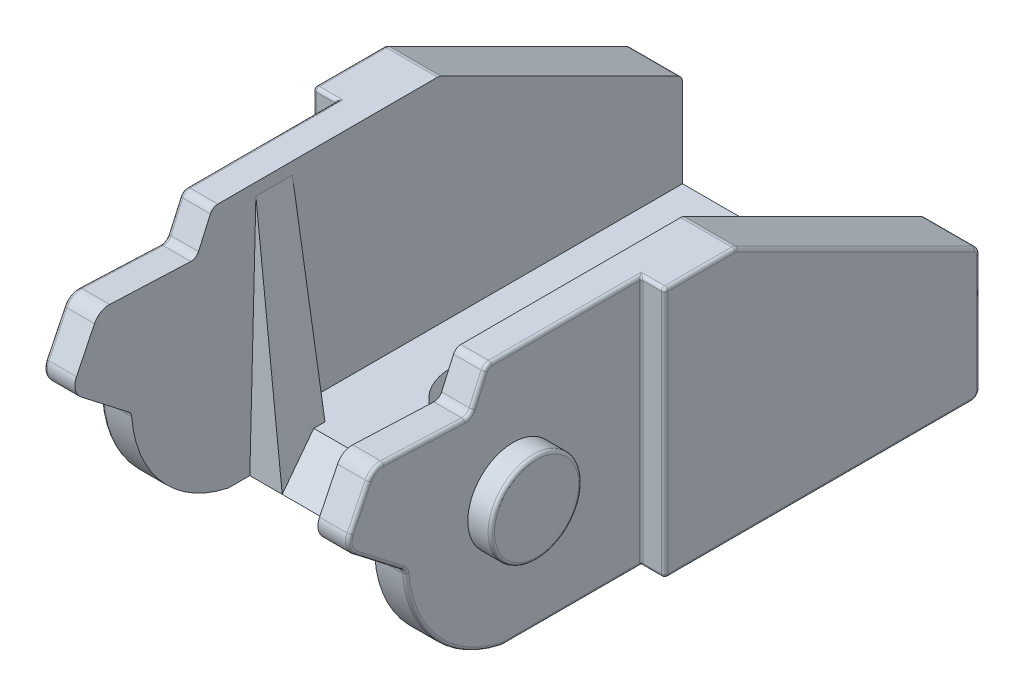
from build123d import *

# Parameters (mm, degrees)
SKETCH1_W               = 38
SKETCH1_H               = 15.5
BOSS_EXTRUDE1_DEPTH     = 10.85
CUT_EXTRUDE1_DEPTH      = 11.85
CUT_EXTRUDE1_DEPTH_BACK = 11.85
FILLET1_R               = 1
FILLET2_R               = 0.5
SKETCH4_R               = 2.8
CUT_EXTRUDE2_DEPTH      = 1.45
SKETCH5_W               = 15
SKETCH5_H               = 13.25
CUT_EXTRUDE3_DEPTH      = 38.495243704
CUT_EXTRUDE4_DEPTH      = 21.7
SKETCH8_W               = 15
SKETCH8_H               = 5.30714421
CUT_EXTRUDE5_DEPTH      = 16.5
CUT_EXTRUDE6_DEPTH      = 2.25
CUT_EXTRUDE6_TAPER      = -30
CUT_EXTRUDE7_DEPTH      = 15
BOSS_EXTRUDE2_DEPTH     = 2
CUT_EXTRUDE8_DEPTH      = 28.35
FILLET3_R               = 0.5
FILLET4_R               = 0.2
SKETCH13_W              = 12
SKETCH13_H              = 4
CUT_EXTRUDE9_DEPTH      = 0.8
BOSS_EXTRUDE3_DEPTH     = 0.15
FILLET5_R               = 0.2
FILLET6_R               = 0.1


with BuildPart() as part:
    # Sketch1 → Boss-Extrude1 (new body, symmetric)
    with BuildSketch(Plane(origin=(0, 0, 0), x_dir=(0, 0, -1), z_dir=(1, 0, 0))):
        with Locations((8.35, 0)):
            Rectangle(SKETCH1_W, SKETCH1_H)
    extrude(amount=BOSS_EXTRUDE1_DEPTH, both=True)

    # Sketch2 → Cut-Extrude1 (cut, two sides)
    with BuildSketch(Plane(origin=(0, 0, 0), x_dir=(0, 0, -1), z_dir=(1, 0, 0))) as cut_extrude1_sk:
        with BuildLine():
            Line((-10.65, 7.75), (-10.65, -7.75))
            Line((-10.65, -7.75), (-0.65, -7.75))
            ThreePointArc((-0.65, -7.75), (-4.852601882, -5.280801613), (-6.65, -0.75))
            Line((-6.65, -0.75), (-10.4, 2.153126358))
            Line((-10.4, 2.153126358), (-8.65, 5.75))
            Line((-8.65, 5.75), (-2.655210596, 5.5))
            Line((-2.655210596, 5.5), (-1.65, 7.75))
            Line((-1.65, 7.75), (-10.65, 7.75))
        make_face()
    extrude(amount=CUT_EXTRUDE1_DEPTH, mode=Mode.SUBTRACT)
    extrude(cut_extrude1_sk.sketch, amount=-CUT_EXTRUDE1_DEPTH_BACK, mode=Mode.SUBTRACT)

    # Fillet1
    fillet1_edges = [part.edges().sort_by_distance(p)[0] for p in [
        (0, 5.75, 8.65),
        (0, 2.153126358, 10.4),
    ]]
    fillet(fillet1_edges, radius=FILLET1_R)

    # Fillet2
    fillet2_edges = [part.edges().sort_by_distance(p)[0] for p in [
        (0, 7.75, 1.65),
        (0, 5.5, 2.655210596),
        (0, -0.75, 6.65),
        (0, -7.75, 0.65),
    ]]
    fillet(fillet2_edges, radius=FILLET2_R)

    # Sketch4 → Cut-Extrude2 (cut)
    with BuildSketch(Plane(origin=(10.85, 0, 0), x_dir=(0, 0, -1), z_dir=(1, 0, 0))):
        with BuildLine():
            Line((7.9, 7.75), (7.9, -7.75))
            Line((7.9, -7.75), (-0.598895402, -7.75))
            ThreePointArc((-0.598895402, -7.75), (-0.65062725, -7.747316615), (-0.701803833, -7.739295263))
            ThreePointArc((-0.701803833, -7.739295263), (-4.798124082, -5.343650392), (-6.636565214, -0.968826038))
            ThreePointArc((-6.636565214, -0.968826038), (-6.694895774, -0.769693924), (-6.829044364, -0.611389757))
            Line((-6.829044364, -0.611389757), (-9.757403786, 1.655649556))
            ThreePointArc((-9.757403786, 1.655649556), (-10.119002319, 2.218800109), (-10.044462115, 2.883883414))
            Line((-10.044462115, 2.883883414), (-8.936529428, 5.161079916))
            ThreePointArc((-8.936529428, 5.161079916), (-8.549859798, 5.582238024), (-7.995644351, 5.722711483))
            Line((-7.995644351, 5.722711483), (-2.994172583, 5.514135692))
            ThreePointArc((-2.994172583, 5.514135692), (-2.710088376, 5.588614452), (-2.516826691, 5.809749804))
            Line((-2.516826691, 5.809749804), (-1.78226263, 7.453951671))
            ThreePointArc((-1.78226263, 7.453951671), (-1.597801688, 7.669509139), (-1.325750072, 7.75))
            Line((-1.325750072, 7.75), (7.9, 7.75))
        make_face()
        Circle(SKETCH4_R, mode=Mode.SUBTRACT)
    cut_extrude2 = extrude(amount=-CUT_EXTRUDE2_DEPTH, mode=Mode.SUBTRACT)

    # Mirror1: Cut-Extrude2 across plane
    add(cut_extrude2.mirror(Plane(origin=(0, 0, 0), x_dir=(0, 0, 1), z_dir=(1, 0, 0))), mode=Mode.SUBTRACT)

    # Sketch5 → Cut-Extrude3 (cut, through all)
    with BuildSketch(Plane(origin=(0, 0, -27.35), x_dir=(-1, 0, 0), z_dir=(0, 0, -1))):
        with Locations((0, 1.125)):
            Rectangle(SKETCH5_W, SKETCH5_H)
    extrude(amount=-CUT_EXTRUDE3_DEPTH, mode=Mode.SUBTRACT)

    # Sketch6 → Cut-Extrude4 (cut)
    with BuildSketch(Plane(origin=(10.85, 0, 0), x_dir=(0, 0, -1), z_dir=(1, 0, 0))):
        Polygon((27.35, 0.25), (27.35, 7.75), (12.35, 7.75), align=None)
    extrude(amount=-CUT_EXTRUDE4_DEPTH, mode=Mode.SUBTRACT)

    # Sketch8 → Cut-Extrude5 (cut, through all)
    with BuildSketch(Plane.XZ.offset(7.75)):
        with Locations((0, 2.003572105)):
            Rectangle(SKETCH8_W, SKETCH8_H)
    extrude(amount=-CUT_EXTRUDE5_DEPTH, mode=Mode.SUBTRACT)

    # Sketch9 → Cut-Extrude6 (cut)
    with BuildSketch(Plane.XZ.offset(7.75)):
        with BuildLine():
            ThreePointArc((-1.5, -17.35), (-3.5, -19.35), (-1.5, -21.35))
            Line((-1.5, -21.35), (1.5, -21.35))
            ThreePointArc((1.5, -21.35), (3.5, -19.35), (1.5, -17.35))
            Line((1.5, -17.35), (-1.5, -17.35))
        make_face()
        with BuildLine():
            ThreePointArc((-1.5, -8.35), (-3.5, -10.35), (-1.5, -12.35))
            Line((-1.5, -12.35), (1.5, -12.35))
            ThreePointArc((1.5, -12.35), (3.5, -10.35), (1.5, -8.35))
            Line((1.5, -8.35), (-1.5, -8.35))
        make_face()
    extrude(amount=-CUT_EXTRUDE6_DEPTH, taper=CUT_EXTRUDE6_TAPER, mode=Mode.SUBTRACT)

    # Sketch10 → Cut-Extrude7 (cut)
    with BuildSketch(Plane.ZY.offset(-7.5)):
        Polygon((-0.65, -7.75), (-0.65, -5.5), (-2.9, -5.5), align=None)
    extrude(amount=CUT_EXTRUDE7_DEPTH, mode=Mode.SUBTRACT)


with BuildPart() as body_2:
    # Sketch11 → Boss-Extrude2 (new body)
    with BuildSketch(Plane.ZY.offset(-7.5)):
        Polygon((-0.65, -7.75), (-3.65, -7.75), (-3.275, 7), (-1.025, 7), align=None)
    extrude(amount=BOSS_EXTRUDE2_DEPTH)

    # Sketch12 → Cut-Extrude8 (cut, through all)
    with BuildSketch(Plane.XY):
        Polygon((7.5, 7), (5.5, 7), (5.5, -7.75), align=None)
    extrude(amount=-CUT_EXTRUDE8_DEPTH, mode=Mode.SUBTRACT)


with BuildPart() as body_3:
    # Mirror2: mirrored copy
    add(body_2.part.mirror(Plane(origin=(0, 0, 0), x_dir=(0, 0, 1), z_dir=(1, 0, 0))))


with BuildPart() as part_1:
    add(part.part)

    # Combine1: union body 2, body 3
    add(body_2.part)
    add(body_3.part)

    # Fillet3
    fillet3_edges = [part_1.edges().sort_by_distance(p)[0] for p in [
        (9.175, 7.75, -12.35),
        (-9.175, 7.75, -12.35),
        (9.175, 0.25, -27.35),
        (-9.175, 0.25, -27.35),
        (0, -7.75, -27.35),
    ]]
    fillet(fillet3_edges, radius=FILLET3_R)

    # Fillet4
    fillet4_edges = [part_1.edges().sort_by_distance(p)[0] for p in [
        (-10.85, -7.75, -17.375),
        (-10.85, -3.654508497, -27.35),
        (10.85, -3.654508497, -27.35),
        (-10.85, 4.042705098, -19.764589803),
        (-10.85, 7.75, -10.065983006),
        (-10.85, 7.736624495, -12.346842472),
        (-10.85, 0.203848562, -27.275325404),
        (-10.85, -7.603553391, -27.203553391),
        (10.85, 4.042705098, -19.764589803),
        (10.85, 7.75, -10.065983006),
        (10.85, 7.736624495, -12.346842472),
        (10.85, 0.203848562, -27.275325404),
        (10.85, -7.603553391, -27.203553391),
        (10.85, -7.75, -17.375),
    ]]
    fillet(fillet4_edges, radius=FILLET4_R)

    # Sketch13 → Cut-Extrude9 (cut)
    with BuildSketch(Plane.XZ.offset(7.75)):
        with Locations((0, -14.85)):
            Rectangle(SKETCH13_W, SKETCH13_H)
    extrude(amount=-CUT_EXTRUDE9_DEPTH, mode=Mode.SUBTRACT)

    # Sketch14 → Boss-Extrude3 (add)
    with BuildSketch(Plane.XZ.offset(6.95)):
        Polygon((-4.746169566, -13.65), (-4.283929983, -13.65), (-4.283929983, -16.15), (-4.508288957, -16.15), (-4.508288957, -13.906410256), (-4.892904342, -13.906410256), align=None)
        with BuildLine():
            add(Edge.make_bspline(
                [(-3.248673572, -14.901001603), (-3.248439274, -14.86093204), (-3.247984145, -14.783096337), (-3.242920987, -14.669678735), (-3.234510029, -14.563278529), (-3.222983334, -14.463890625), (-3.208956205, -14.371489364), (-3.190230857, -14.286321681), (-3.168935998, -14.20799339), (-3.14425568, -14.13624907), (-3.116407259, -14.070122139), (-3.086097073, -14.008389852), (-3.05212222, -13.951145615), (-3.016424425, -13.897475765), (-2.977558659, -13.84825884), (-2.936630952, -13.802799795), (-2.892043897, -13.762149259), (-2.845313177, -13.725116186), (-2.796015703, -13.692652278), (-2.745556655, -13.664057464), (-2.693588723, -13.639628988), (-2.639970021, -13.620421534), (-2.585182479, -13.604556643), (-2.529034574, -13.593707395), (-2.4714336, -13.586881032), (-2.432554004, -13.586228412), (-2.412836233, -13.585897436)],
                knots=[0, 0, 0, 0, 0.000120202, 0.000233494, 0.000340503, 0.000440329, 0.000533614, 0.000620743, 0.000701782, 0.00077701, 0.000848163, 0.00091692, 0.000983142, 0.00104773, 0.001110145, 0.00117112, 0.001231017, 0.00129093, 0.001349822, 0.001407902, 0.001464811, 0.001521845, 0.001578597, 0.001635759, 0.00169322, 0.001752349, 0.001752349, 0.001752349, 0.001752349], degree=3))
            add(Edge.make_bspline(
                [(-2.412836233, -13.585897436), (-2.392953748, -13.586245875), (-2.353413742, -13.586938812), (-2.294956331, -13.593598771), (-2.237849415, -13.604649573), (-2.182336459, -13.620307412), (-2.127961469, -13.639732895), (-2.075149749, -13.664080836), (-2.023573262, -13.692422884), (-1.974051628, -13.725725654), (-1.926041189, -13.762855851), (-1.880721215, -13.804829186), (-1.838087582, -13.851221842), (-1.797605221, -13.901537459), (-1.760422652, -13.956741091), (-1.725013057, -14.015872598), (-1.693318746, -14.079966073), (-1.662793978, -14.147952122), (-1.63644613, -14.221711878), (-1.612684527, -14.300829564), (-1.593485263, -14.386239698), (-1.577492926, -14.477494158), (-1.565103715, -14.574928075), (-1.556080399, -14.678332586), (-1.55131391, -14.787775722), (-1.550416266, -14.862602757), (-1.549955624, -14.901001603)],
                knots=[0, 0, 0, 0, 5.9629e-05, 0.000118583, 0.000176236, 0.000233953, 0.000291458, 0.000349276, 0.00040823, 0.000467817, 0.000528123, 0.000590144, 0.000652872, 0.000717006, 0.00078368, 0.000852391, 0.000923612, 0.000998055, 0.00107584, 0.001158394, 0.001245741, 0.001338285, 0.001436244, 0.001540301, 0.001649591, 0.001764792, 0.001764792, 0.001764792, 0.001764792], degree=3))
            add(Edge.make_bspline(
                [(-1.549955624, -14.901001603), (-1.550421041, -14.939232965), (-1.551327888, -15.013725217), (-1.556026965, -15.122675913), (-1.56528313, -15.225531659), (-1.576861693, -15.322539132), (-1.592898095, -15.413294574), (-1.612616071, -15.498112037), (-1.634509159, -15.577357802), (-1.661534011, -15.650382668), (-1.69111309, -15.718205327), (-1.723295373, -15.781539004), (-1.75777382, -15.840943499), (-1.79533721, -15.895943318), (-1.835375362, -15.946928074), (-1.878745211, -15.992997804), (-1.924224201, -16.03526257), (-1.972375926, -16.072870875), (-2.022669891, -16.105788593), (-2.074069232, -16.135227057), (-2.127485934, -16.158964696), (-2.181709472, -16.179346869), (-2.237515448, -16.19491862), (-2.294834298, -16.20568566), (-2.353374467, -16.21323698), (-2.392947013, -16.213813037), (-2.412836233, -16.214102564)],
                knots=[0, 0, 0, 0, 0.000114701, 0.00022349, 0.000327048, 0.000424447, 0.000516498, 0.000603358, 0.000685631, 0.000762946, 0.000836729, 0.000907504, 0.00097596, 0.001042634, 0.00110716, 0.001170229, 0.001232249, 0.001293259, 0.001353263, 0.001412461, 0.001470735, 0.001528412, 0.001586129, 0.001644273, 0.001703285, 0.001762914, 0.001762914, 0.001762914, 0.001762914], degree=3))
            add(Edge.make_bspline(
                [(-2.412836233, -16.214102564), (-2.432553457, -16.213769453), (-2.471431975, -16.213112623), (-2.52904085, -16.206317101), (-2.584956881, -16.195391741), (-2.639455991, -16.180094167), (-2.692817788, -16.161369284), (-2.744315135, -16.136973795), (-2.794520623, -16.108878032), (-2.843300306, -16.076881302), (-2.889737564, -16.040222957), (-2.934093711, -15.999677037), (-2.975254439, -15.954231743), (-3.013564507, -15.904604655), (-3.04997457, -15.851252339), (-3.08346698, -15.793446358), (-3.114446161, -15.731415922), (-3.14276294, -15.664760272), (-3.167869128, -15.592506752), (-3.190046063, -15.513828767), (-3.207556175, -15.428031884), (-3.222544, -15.335805193), (-3.234632845, -15.236752386), (-3.242885935, -15.130819687), (-3.247986874, -15.01807311), (-3.248440496, -14.940737556), (-3.248673572, -14.901001603)],
                knots=[0, 0, 0, 0, 5.9128e-05, 0.00011659, 0.000173751, 0.000229886, 0.000286279, 0.000343188, 0.000400586, 0.000458784, 0.000517993, 0.000577891, 0.000638865, 0.000701676, 0.000765848, 0.000832502, 0.000901931, 0.00097374, 0.001049606, 0.001131261, 0.001218775, 0.00131214, 0.001411527, 0.001518038, 0.001630829, 0.001750029, 0.001750029, 0.001750029, 0.001750029], degree=3))
        make_face()
        with BuildLine():
            add(Edge.make_bspline(
                [(-3.024314598, -14.9), (-3.024229279, -14.933391928), (-3.024063691, -14.998199103), (-3.019737833, -15.09237286), (-3.01384481, -15.18020881), (-3.006243884, -15.261818478), (-2.994956063, -15.33692563), (-2.982308358, -15.406046832), (-2.966916865, -15.468816288), (-2.948706138, -15.525664724), (-2.927963926, -15.577556916), (-2.905316881, -15.625843498), (-2.880987793, -15.671094881), (-2.853759828, -15.712904601), (-2.824106211, -15.751409004), (-2.792696741, -15.787289599), (-2.758359181, -15.819287442), (-2.710856507, -15.857663767), (-2.64814474, -15.897320292), (-2.569130129, -15.931853213), (-2.487938378, -15.953554967), (-2.432830342, -15.956314793), (-2.405324213, -15.957692308)],
                knots=[0, 0, 0, 0, 0.000100165, 0.000194401, 0.000282747, 0.000364271, 0.000440195, 0.000510522, 0.000575018, 0.000633934, 0.000689453, 0.00074255, 0.000793869, 0.000843459, 0.000892039, 0.000939576, 0.000986341, 0.001032643, 0.001122675, 0.0012079, 0.001290617, 0.001373047, 0.001373047, 0.001373047, 0.001373047], degree=3))
            add(Edge.make_bspline(
                [(-2.405324213, -15.957692308), (-2.377640162, -15.956551036), (-2.322329217, -15.954270848), (-2.241519363, -15.93227175), (-2.163069171, -15.899079222), (-2.101589213, -15.859831003), (-2.054815968, -15.822453625), (-2.021303832, -15.790586019), (-1.990545226, -15.754903257), (-1.961372315, -15.71640376), (-1.934615833, -15.674351986), (-1.91028502, -15.628950146), (-1.888082629, -15.580072162), (-1.875433311, -15.54595092), (-1.86896604, -15.528505609)],
                knots=[0, 0, 0, 0, 8.2888e-05, 0.000165605, 0.000249513, 0.000337741, 0.000383339, 0.000429032, 0.000476238, 0.000524515, 0.000573834, 0.000625593, 0.000678935, 0.000734738, 0.000734738, 0.000734738, 0.000734738], degree=3))
            add(Edge.make_bspline(
                [(-1.86896604, -15.528505609), (-1.861429063, -15.506198652), (-1.846125768, -15.460905963), (-1.826403072, -15.390646212), (-1.810870644, -15.316929952), (-1.796896811, -15.240197726), (-1.787358914, -15.159883654), (-1.779681905, -15.076236237), (-1.775159985, -14.989192406), (-1.774599449, -14.930053127), (-1.774314598, -14.9)],
                knots=[0, 0, 0, 0, 7.0633e-05, 0.000143414, 0.000218756, 0.000296563, 0.000377314, 0.000461285, 0.000548541, 0.000638698, 0.000638698, 0.000638698, 0.000638698], degree=3))
            add(Edge.make_bspline(
                [(-1.774314598, -14.9), (-1.77470759, -14.869951734), (-1.775476367, -14.811170902), (-1.77841493, -14.725086487), (-1.786003197, -14.643323801), (-1.79443114, -14.565530606), (-1.806857726, -14.492137533), (-1.82025616, -14.422530172), (-1.838257025, -14.357570868), (-1.857485436, -14.296242596), (-1.879492862, -14.239242128), (-1.903718386, -14.186303709), (-1.929591071, -14.137171763), (-1.957692671, -14.091981091), (-1.987689588, -14.050529274), (-2.020373551, -14.013647421), (-2.054448103, -13.980192444), (-2.102174665, -13.942004894), (-2.1646563, -13.903067969), (-2.242403191, -13.867235283), (-2.323310794, -13.846657932), (-2.378006119, -13.843756726), (-2.405324213, -13.842307692)],
                knots=[0, 0, 0, 0, 9.0157e-05, 0.000176366, 0.000258297, 0.000336443, 0.000411035, 0.000481554, 0.000548977, 0.00061312, 0.000674316, 0.000732135, 0.000787694, 0.000840779, 0.000891664, 0.00094099, 0.000988447, 0.001034749, 0.001124091, 0.001208602, 0.001290711, 0.001372642, 0.001372642, 0.001372642, 0.001372642], degree=3))
            add(Edge.make_bspline(
                [(-2.405324213, -13.842307692), (-2.432974636, -13.843758726), (-2.488325855, -13.846663436), (-2.570074394, -13.867158617), (-2.648434645, -13.902882164), (-2.710751055, -13.942133859), (-2.758510903, -13.979518367), (-2.792141398, -14.011937262), (-2.823674378, -14.047398873), (-2.852722736, -14.086257383), (-2.879929366, -14.12801836), (-2.904915804, -14.173010335), (-2.927428182, -14.221461309), (-2.948202851, -14.273330192), (-2.966469128, -14.330173723), (-2.981536245, -14.392865862), (-2.995455568, -14.461767213), (-3.005309332, -14.537281147), (-3.014069157, -14.618911257), (-3.019698692, -14.706966484), (-3.024078161, -14.801298184), (-3.024234207, -14.86644044), (-3.024314598, -14.9)],
                knots=[0, 0, 0, 0, 8.2929e-05, 0.000166009, 0.000250977, 0.00034032, 0.000386309, 0.000432711, 0.000480247, 0.000528525, 0.000578114, 0.000629675, 0.000682772, 0.00073829, 0.000797207, 0.000861703, 0.000931633, 0.001007981, 0.001090055, 0.001177901, 0.001272637, 0.001373303, 0.001373303, 0.001373303, 0.001373303], degree=3))
        make_face(mode=Mode.SUBTRACT)
        Polygon((-1.171750496, -13.65), (-0.912836233, -13.65), (-0.258288957, -14.672636218), (0.396258319, -13.65), (0.655172581, -13.65), (-0.128581425, -14.874959936), (0.687223863, -16.15), (0.428309601, -16.15), (-0.258288957, -15.077283654), (-0.944887515, -16.15), (-1.203801778, -16.15), (-0.387495688, -14.874959936), align=None)
        Polygon((1.532676588, -13.65), (1.994916171, -13.65), (1.994916171, -16.15), (1.770557197, -16.15), (1.770557197, -13.906410256), (1.385941812, -13.906410256), align=None)
        with BuildLine():
            Line((4.600685402, -13.65), (4.600685402, -13.906410256))
            Line((4.600685402, -13.906410256), (3.750324825, -13.906410256))
            Line((3.750324825, -13.906410256), (3.61560928, -14.56396234))
            add(Edge.make_bspline(
                [(3.61560928, -14.56396234), (3.642077762, -14.556655003), (3.693356259, -14.542498193), (3.769041874, -14.526779786), (3.840893448, -14.517304468), (3.887518712, -14.516010675), (3.910080434, -14.515384615)],
                knots=[0, 0, 0, 0, 8.2359e-05, 0.000159557, 0.000231736, 0.000299411, 0.000299411, 0.000299411, 0.000299411], degree=3))
            add(Edge.make_bspline(
                [(3.910080434, -14.515384615), (3.937997391, -14.515988855), (3.992889103, -14.517176942), (4.073202637, -14.528585405), (4.149868989, -14.546542487), (4.222727825, -14.571628574), (4.291913933, -14.603706955), (4.356790762, -14.643778341), (4.418332129, -14.690587863), (4.475433981, -14.744405729), (4.527237059, -14.803635455), (4.572784194, -14.867319649), (4.611471759, -14.934839408), (4.642586584, -15.006839842), (4.667432537, -15.082524952), (4.683969676, -15.162691082), (4.694981611, -15.246582597), (4.696211887, -15.303943004), (4.696839248, -15.333193109)],
                knots=[0, 0, 0, 0, 8.3707e-05, 0.000164589, 0.000242817, 0.000319629, 0.000395356, 0.000471111, 0.000547937, 0.000626944, 0.000706092, 0.000783637, 0.000861469, 0.000939066, 0.001018569, 0.001099996, 0.001184289, 0.001271999, 0.001271999, 0.001271999, 0.001271999], degree=3))
            add(Edge.make_bspline(
                [(4.696839248, -15.333193109), (4.696364194, -15.353566124), (4.695420507, -15.394036829), (4.690621516, -15.454139829), (4.681381718, -15.512970424), (4.668976201, -15.570536419), (4.652874474, -15.626728827), (4.633382293, -15.68170849), (4.609527987, -15.735133209), (4.583362719, -15.787508491), (4.553900949, -15.837650282), (4.521202015, -15.884542416), (4.486655236, -15.928888331), (4.449482818, -15.970212426), (4.40933925, -16.008243153), (4.366710702, -16.043206211), (4.321937331, -16.075692876), (4.274326444, -16.104384444), (4.224938956, -16.130786555), (4.173061658, -16.152446225), (4.119875444, -16.171810888), (4.064614818, -16.187246264), (4.007404952, -16.199340946), (3.948151541, -16.207555661), (3.887165348, -16.213538831), (3.845826053, -16.213913371), (3.824944216, -16.214102564)],
                knots=[0, 0, 0, 0, 6.1131e-05, 0.000121435, 0.000180718, 0.000239655, 0.00029799, 0.000355966, 0.000414493, 0.000473397, 0.000531543, 0.000588777, 0.00064478, 0.000700095, 0.000755356, 0.000810501, 0.0008654, 0.000921142, 0.000977145, 0.001033237, 0.00108963, 0.001146863, 0.001205206, 0.001264911, 0.001326257, 0.001388875, 0.001388875, 0.001388875, 0.001388875], degree=3))
            add(Edge.make_bspline(
                [(3.824944216, -16.214102564), (3.800034087, -16.213609108), (3.751026351, -16.212638293), (3.679225946, -16.202482232), (3.610144084, -16.187936577), (3.544336869, -16.166053527), (3.481214538, -16.138634031), (3.421626883, -16.103979623), (3.364051328, -16.064708834), (3.310828445, -16.018365725), (3.261431221, -15.967711667), (3.217212286, -15.912741923), (3.17783116, -15.85436375), (3.143918483, -15.79229364), (3.114991325, -15.726694689), (3.092266334, -15.657321117), (3.073924652, -15.5845354), (3.066165066, -15.53442575), (3.062223863, -15.508974359)],
                knots=[0, 0, 0, 0, 7.468e-05, 0.000146924, 0.000217159, 0.000286208, 0.0003546, 0.000423239, 0.000492699, 0.000563369, 0.000634555, 0.000704712, 0.000774716, 0.00084554, 0.000916628, 0.000989477, 0.001064298, 0.001141525, 0.001141525, 0.001141525, 0.001141525], degree=3))
            Line((3.062223863, -15.508974359), (3.286582838, -15.508974359))
            add(Edge.make_bspline(
                [(3.286582838, -15.508974359), (3.292103236, -15.532814682), (3.302713748, -15.578637107), (3.326003568, -15.643016637), (3.354479194, -15.700387511), (3.388339442, -15.751508642), (3.428732321, -15.796086497), (3.474824771, -15.83581297), (3.526501716, -15.871652348), (3.583925451, -15.901525753), (3.644506222, -15.927003434), (3.707911372, -15.94396893), (3.772414477, -15.955898139), (3.816041884, -15.957092254), (3.837965049, -15.957692308)],
                knots=[0, 0, 0, 0, 7.3364e-05, 0.000141009, 0.000204839, 0.00026512, 0.000324344, 0.000384694, 0.000447345, 0.000512537, 0.000578567, 0.000644057, 0.0007091, 0.000774799, 0.000774799, 0.000774799, 0.000774799], degree=3))
            add(Edge.make_bspline(
                [(3.837965049, -15.957692308), (3.859363938, -15.957106038), (3.901498526, -15.955951667), (3.963506659, -15.947066659), (4.023372998, -15.933382679), (4.080506824, -15.912904211), (4.135907924, -15.888015127), (4.188174902, -15.856075787), (4.238819815, -15.819318631), (4.286268481, -15.777206752), (4.329725231, -15.730799828), (4.36812246, -15.681173118), (4.40010597, -15.628232513), (4.427058905, -15.572894547), (4.447525547, -15.514552721), (4.462126248, -15.453480453), (4.470699861, -15.389526895), (4.471879275, -15.34590596), (4.472480274, -15.323677885)],
                knots=[0, 0, 0, 0, 6.4173e-05, 0.000126357, 0.00018758, 0.000248084, 0.00030814, 0.000369463, 0.000431468, 0.000495682, 0.000559459, 0.000621963, 0.000683545, 0.000744694, 0.000806309, 0.000868622, 0.000932791, 0.000999465, 0.000999465, 0.000999465, 0.000999465], degree=3))
            add(Edge.make_bspline(
                [(4.472480274, -15.323677885), (4.472009931, -15.303623776), (4.471089303, -15.264370713), (4.463567467, -15.206942708), (4.450483915, -15.152604821), (4.432324001, -15.101094654), (4.40926721, -15.052363623), (4.381091272, -15.006361438), (4.347267417, -14.963694414), (4.308630353, -14.92434259), (4.266303181, -14.888024822), (4.219557651, -14.85706476), (4.169371989, -14.831019105), (4.116350846, -14.808541963), (4.059233062, -14.792398574), (3.999149753, -14.780278655), (3.935452104, -14.773267682), (3.891901613, -14.772294905), (3.86951553, -14.771794872)],
                knots=[0, 0, 0, 0, 6.0148e-05, 0.000117732, 0.000173364, 0.000227533, 0.000281297, 0.000334808, 0.00038901, 0.000444257, 0.000500044, 0.00055602, 0.000612022, 0.000669499, 0.000728453, 0.00078974, 0.000853229, 0.000920383, 0.000920383, 0.000920383, 0.000920383], degree=3))
            add(Edge.make_bspline(
                [(3.86951553, -14.771794872), (3.850137724, -14.77220958), (3.81012747, -14.773065847), (3.748754022, -14.779370487), (3.684259935, -14.789541412), (3.616892438, -14.803531588), (3.546449218, -14.8218395), (3.473078931, -14.843778429), (3.396627312, -14.870008429), (3.345114652, -14.889817153), (3.31863412, -14.9)],
                knots=[0, 0, 0, 0, 5.8127e-05, 0.000120018, 0.000184899, 0.000253946, 0.000326339, 0.000403184, 0.000483637, 0.000568745, 0.000568745, 0.000568745, 0.000568745], degree=3))
            Line((3.31863412, -14.9), (3.575044376, -13.65))
            Line((3.575044376, -13.65), (4.600685402, -13.65))
        make_face()
    extrude(amount=BOSS_EXTRUDE3_DEPTH)

    # Fillet5
    fillet5_edges = [part_1.edges().sort_by_distance(p)[0] for p in [
        (10.85, 0, 2.8),
        (-9.4, 7.75, -3.287124964),
        (-9.4, 7.669509139, 1.597801688),
        (-9.4, 6.631850738, 2.14954466),
        (-9.4, 5.588614452, 2.710088376),
        (-9.4, 5.618423588, 5.494908467),
        (-9.4, 5.582238024, 8.549859798),
        (-9.4, 4.022481665, 9.490495771),
        (-9.4, 2.218800109, 10.119002319),
        (-9.4, 0.522129899, 8.293224075),
        (-9.4, -0.769693924, 6.694895774),
        (-9.4, -5.343650392, 4.798124082),
        (-9.4, -7.747316615, 0.65062725),
        (-9.4, -7.75, -3.650552299),
        (-10.85, 0, 2.8),
        (-10.025, 7.75, -7.9),
        (-10.025, -7.75, -7.9),
        (-10.85, 0, -7.9),
        (-10.791421356, 7.691421356, -7.9),
        (-10.791421356, -7.691421356, -7.9),
        (10.85, 0, -7.9),
        (10.791421356, 7.691421356, -7.9),
        (10.791421356, -7.691421356, -7.9),
        (9.4, 7.75, -3.287124964),
        (10.025, 7.75, -7.9),
        (9.4, -7.75, -3.650552299),
        (10.025, -7.75, -7.9),
        (9.4, -7.747316615, 0.65062725),
        (9.4, -5.343650392, 4.798124082),
        (9.4, -0.769693924, 6.694895774),
        (9.4, 0.522129899, 8.293224075),
        (9.4, 2.218800109, 10.119002319),
        (9.4, 4.022481665, 9.490495771),
        (9.4, 5.582238024, 8.549859798),
        (9.4, 5.618423588, 5.494908467),
        (9.4, 5.588614452, 2.710088376),
        (9.4, 6.631850738, 2.14954466),
        (9.4, 7.669509139, 1.597801688),
    ]]
    fillet(fillet5_edges, radius=FILLET5_R)

    # Fillet6
    fillet6_edges = [part_1.edges().sort_by_distance(p)[0] for p in [
        (9.4, 0, -7.9),
        (-9.4, 0, -7.9),
        (9.329209781, 7.702659203, -7.970790219),
        (9.329209781, -7.702659203, -7.970790219),
        (-9.329209781, 7.702659203, -7.970790219),
        (-9.329209781, -7.702659203, -7.970790219),
    ]]
    fillet(fillet6_edges, radius=FILLET6_R)


solid = part_1.part
